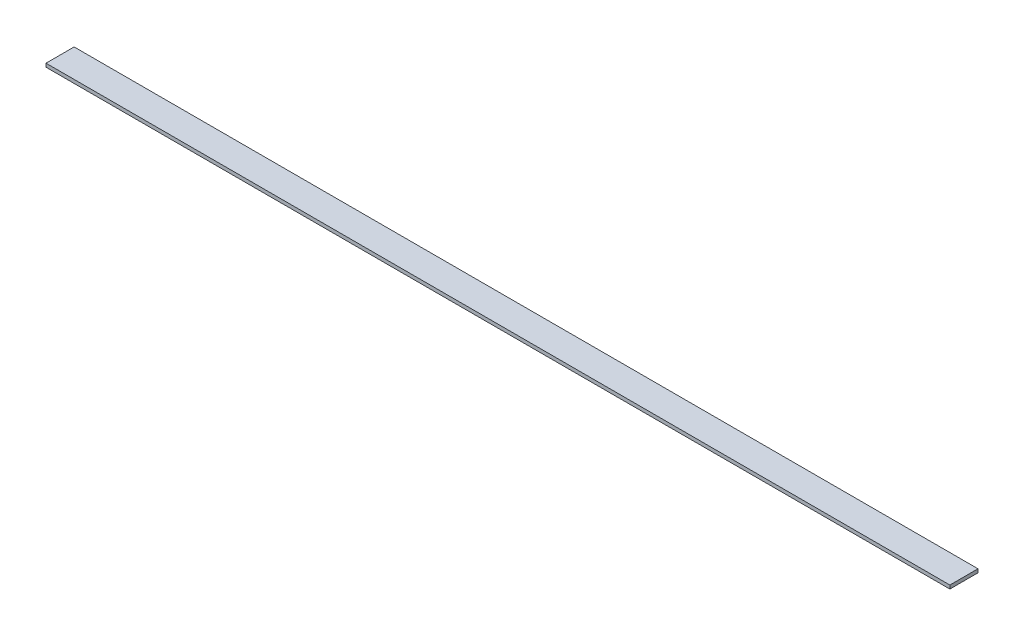
from build123d import *

# Parameters (mm, degrees)
SKETCH2_W           = 1631.95
SKETCH2_H           = 50.8
BOSS_EXTRUDE1_DEPTH = 6.35


with BuildPart() as part:
    # Sketch2 → Boss-Extrude1 (new body)
    with BuildSketch(Plane(origin=(0, 0, 0), x_dir=(1, 0, 0), z_dir=(0, 1, 0))):
        with Locations((815.975, 25.4)):
            Rectangle(SKETCH2_W, SKETCH2_H)
    extrude(amount=BOSS_EXTRUDE1_DEPTH)


solid = part.part
